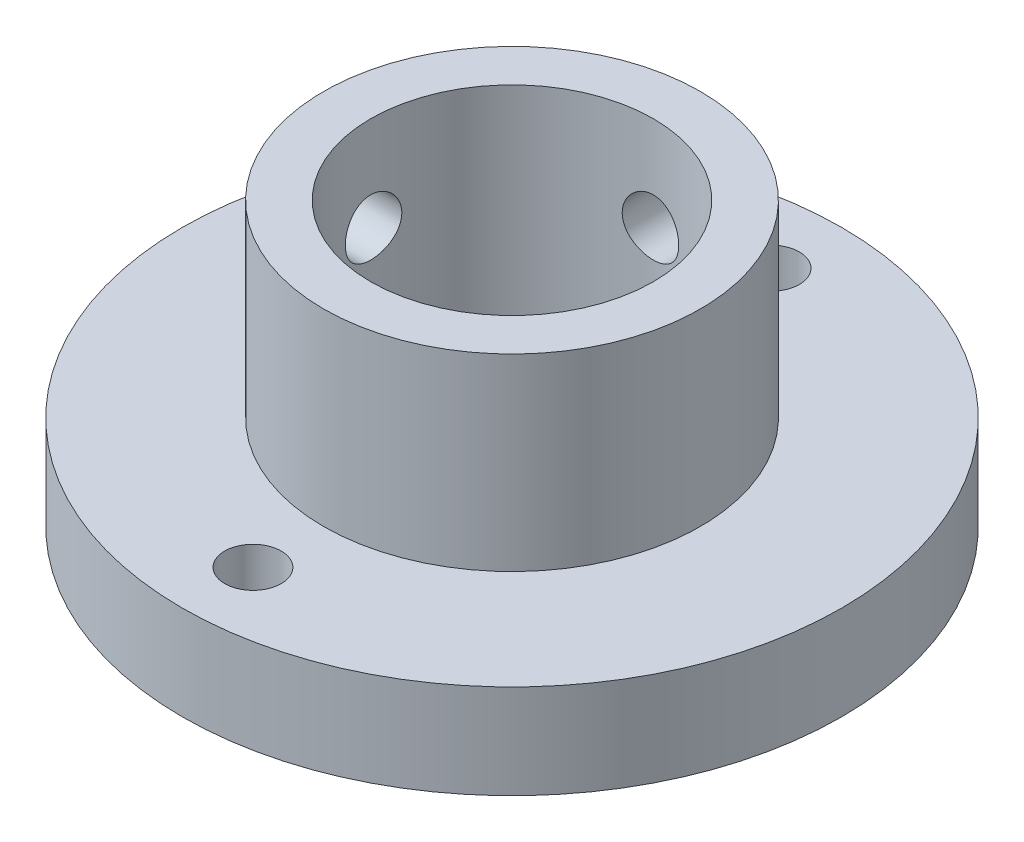
from build123d import *

# Parameters (mm, degrees)
ESBO_O1_R                = 17.5
RESSALTO_EXTRUS_O1_DEPTH = 5
ESBO_O2_R                = 10
RESSALTO_EXTRUS_O2_DEPTH = 10
ESBO_O3_R                = 7.5
CORTE_EXTRUS_O1_DEPTH    = 16
ESBO_O4_R                = 1.5
CORTE_EXTRUS_O2_DEPTH    = 10
ESBO_O5_R                = 1.5
CORTE_EXTRUS_O3_DEPTH    = 10
ESBO_O6_R                = 1.5
CORTE_EXTRUS_O4_DEPTH    = 10


with BuildPart() as part:
    # Esboço1 → Ressalto-extrusão1 (new body)
    with BuildSketch(Plane(origin=(0, 0, 0), x_dir=(1, 0, 0), z_dir=(0, 1, 0))):
        Circle(ESBO_O1_R)
    extrude(amount=RESSALTO_EXTRUS_O1_DEPTH)

    # Esboço2 → Ressalto-extrusão2 (add)
    with BuildSketch(Plane(origin=(0, 5, 0), x_dir=(1, 0, 0), z_dir=(0, 1, 0))):
        Circle(ESBO_O2_R)
    extrude(amount=RESSALTO_EXTRUS_O2_DEPTH)

    # Esboço3 → Corte-extrusão1 (cut, through all)
    with BuildSketch(Plane(origin=(0, 15, 0), x_dir=(1, 0, 0), z_dir=(0, 1, 0))):
        Circle(ESBO_O3_R)
    extrude(amount=-CORTE_EXTRUS_O1_DEPTH, mode=Mode.SUBTRACT)

    # Esboço4 → Corte-extrusão2 (cut)
    with BuildSketch(Plane(origin=(0, 5, 0), x_dir=(1, 0, 0), z_dir=(0, 1, 0))):
        with Locations((0, 13.75)):
            Circle(ESBO_O4_R)
        with Locations((0, -13.75)):
            Circle(ESBO_O4_R)
    extrude(amount=-CORTE_EXTRUS_O2_DEPTH, mode=Mode.SUBTRACT)

    # Esboço5 → Corte-extrusão3 (cut)
    with BuildSketch(Plane.XY):
        with Locations((0, 10)):
            Circle(ESBO_O5_R)
    extrude(amount=-CORTE_EXTRUS_O3_DEPTH, mode=Mode.SUBTRACT)

    # Esboço6 → Corte-extrusão4 (cut)
    with BuildSketch(Plane(origin=(0, 0, 0), x_dir=(0, 0, -1), z_dir=(1, 0, 0))):
        with Locations((0, 10)):
            Circle(ESBO_O6_R)
    extrude(amount=-CORTE_EXTRUS_O4_DEPTH, mode=Mode.SUBTRACT)


solid = part.part
